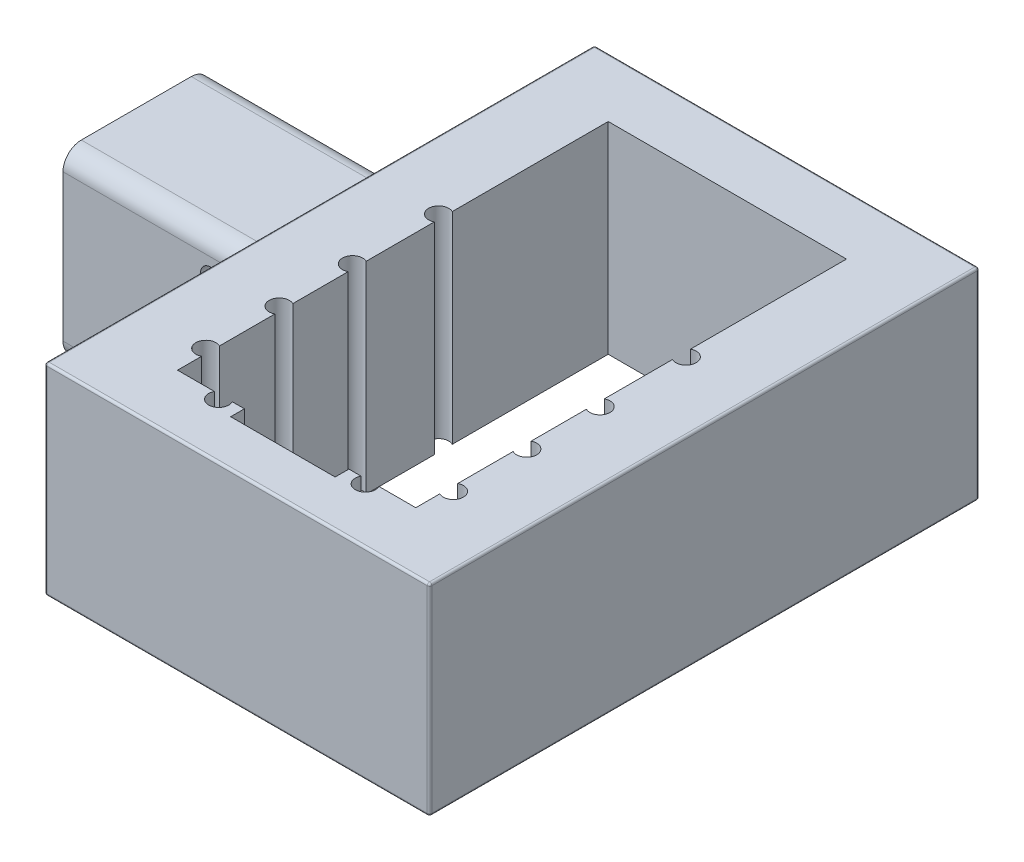
from build123d import *

# Parameters (mm, degrees)
BOSS_EXTRUDE3_DEPTH      = 3.9
BOSS_EXTRUDE3_DEPTH_BACK = 16.1
SKETCH8_R                = 1.089581078
CUT_EXTRUDE2_DEPTH       = 23.9
SKETCH9_R                = 1.096990471
CUT_EXTRUDE3_DEPTH       = 23.9
SKETCH14_W               = 60
SKETCH14_H               = 22
BOSS_EXTRUDE4_DEPTH      = 42
CUT_EXTRUDE4_DEPTH       = 22
CUT_EXTRUDE4_DEPTH_BACK  = 25
FILLET5_R                = 0.25
SKETCH20_R               = 1.1
CUT_EXTRUDE6_DEPTH       = 110
SKETCH23_R               = 1.1
CUT_EXTRUDE7_DEPTH       = 110


with BuildPart() as part:
    # Sketch1 → Boss-Extrude3 (new body, two sides)
    with BuildSketch(Plane(origin=(0, 0, 0), x_dir=(0, 0, -1), z_dir=(1, 0, 0))) as boss_extrude3_sk:
        with BuildLine():
            ThreePointArc((-6, -10), (-7.414213562, -9.414213562), (-8, -8))
            Line((-8, -8), (-8, 8))
            ThreePointArc((-8, 8), (-7.414213562, 9.414213562), (-6, 10))
            Line((-6, 10), (6, 10))
            ThreePointArc((6, 10), (7.414213562, 9.414213562), (8, 8))
            Line((8, 8), (8, -8))
            ThreePointArc((8, -8), (7.414213562, -9.414213562), (6, -10))
            Line((6, -10), (-6, -10))
        make_face()
        with BuildLine():
            ThreePointArc((-6, -7.25), (-5.926776695, -7.426776695), (-5.75, -7.5))
            Line((-5.75, -7.5), (5.75, -7.5))
            ThreePointArc((5.75, -7.5), (5.926776695, -7.426776695), (6, -7.25))
            Line((6, -7.25), (6, 7.25))
            ThreePointArc((6, 7.25), (5.926776695, 7.426776695), (5.75, 7.5))
            Line((5.75, 7.5), (-5.75, 7.5))
            ThreePointArc((-5.75, 7.5), (-5.926776695, 7.426776695), (-6, 7.25))
            Line((-6, 7.25), (-6, -7.25))
        make_face(mode=Mode.SUBTRACT)
    extrude(amount=BOSS_EXTRUDE3_DEPTH)
    extrude(boss_extrude3_sk.sketch, amount=-BOSS_EXTRUDE3_DEPTH_BACK)

    # Sketch8 → Cut-Extrude2 (cut)
    with BuildSketch(Plane.XY.offset(8)):
        with Locations((0, 5.960174238)):
            Circle(SKETCH8_R)
    extrude(amount=-CUT_EXTRUDE2_DEPTH, mode=Mode.SUBTRACT)

    # Sketch9 → Cut-Extrude3 (cut)
    with BuildSketch(Plane.XY.offset(-8)):
        with Locations((0.217674261, -5.978268898)):
            Circle(SKETCH9_R)
    extrude(amount=CUT_EXTRUDE3_DEPTH, mode=Mode.SUBTRACT)

    # Sketch14 → Boss-Extrude4 (add)
    with BuildSketch(Plane(origin=(3.9, 0, 0), x_dir=(0, 0, -1), z_dir=(1, 0, 0))):
        Rectangle(SKETCH14_W, SKETCH14_H)
    extrude(amount=BOSS_EXTRUDE4_DEPTH)

    # Sketch19 → Cut-Extrude4 (cut, two sides)
    with BuildSketch(Plane(origin=(0, 0, 0), x_dir=(1, 0, 0), z_dir=(0, 1, 0))) as cut_extrude4_sk:
        Polygon((11.9, -23.5), (19.2, -23.5), (19.2, -25), (30.6, -25), (30.6, -23.5), (37.9, -23.5), (37.9, 23.5), (11.9, 23.5), align=None)
    extrude(amount=CUT_EXTRUDE4_DEPTH, mode=Mode.SUBTRACT)
    extrude(cut_extrude4_sk.sketch, amount=-CUT_EXTRUDE4_DEPTH_BACK, mode=Mode.SUBTRACT)

    # Fillet5
    fillet5_edges = [part.edges().sort_by_distance(p)[0] for p in [
        (3.9, -11, 0),
        (3.9, 0, 30),
        (3.9, 0, -30),
        (24.9, -11, -30),
        (3.9, 11, 0),
        (24.9, 11, -30),
        (45.9, 0, 30),
        (24.9, 11, 30),
        (45.9, -11, 0),
        (24.9, -11, 30),
        (45.9, 0, -30),
        (45.9, 11, 0),
        (3.9, -9.414213562, 7.414213562),
        (3.9, -10, 0),
        (3.9, 9.414213562, -7.414213562),
        (3.9, 0, 8),
        (3.9, -9.414213562, -7.414213562),
        (3.9, 0, -8),
        (3.9, 10, 0),
        (3.9, 9.414213562, 7.414213562),
    ]]
    fillet(fillet5_edges, radius=FILLET5_R)

    # Sketch20 → Cut-Extrude6 (cut)
    with BuildSketch(Plane(origin=(0, 11, 0), x_dir=(1, 0, 0), z_dir=(0, 1, 0))):
        with Locations((11.4, 5.5)):
            Circle(SKETCH20_R)
        with Locations((11.4, -3.9)):
            Circle(SKETCH20_R)
        with Locations((11.4, -11.9)):
            Circle(SKETCH20_R)
        with Locations((11.4, -19.9)):
            Circle(SKETCH20_R)
        with Locations((38.4, -19.9)):
            Circle(SKETCH20_R)
        with Locations((38.4, -11.9)):
            Circle(SKETCH20_R)
        with Locations((38.4, -3.9)):
            Circle(SKETCH20_R)
        with Locations((38.4, 5.5)):
            Circle(SKETCH20_R)
    extrude(amount=-CUT_EXTRUDE6_DEPTH, mode=Mode.SUBTRACT)

    # Sketch23 → Cut-Extrude7 (cut)
    with BuildSketch(Plane(origin=(0, 11, 0), x_dir=(1, 0, 0), z_dir=(0, 1, 0))):
        with Locations((16.9, -24)):
            Circle(SKETCH23_R)
        with Locations((32.9, -24)):
            Circle(SKETCH23_R)
    extrude(amount=-CUT_EXTRUDE7_DEPTH, mode=Mode.SUBTRACT)


solid = part.part
